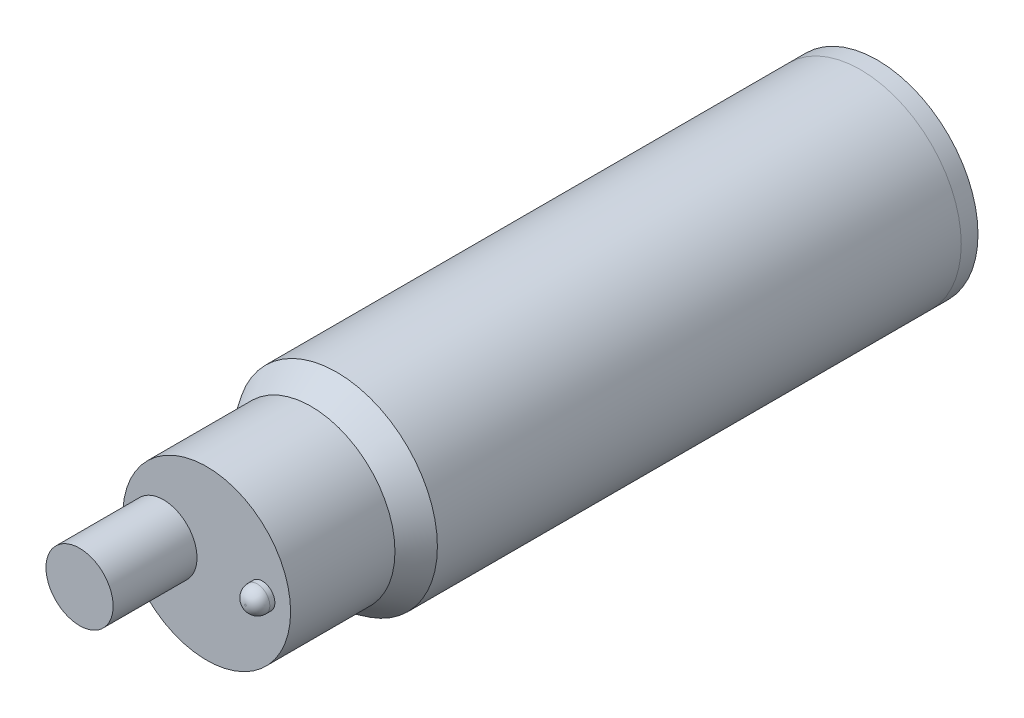
from build123d import *

# Parameters (mm, degrees)
SKETCH2_R           = 0.75
BOSS_EXTRUDE1_DEPTH = 1
FILLET1_R           = 0.7
SKETCH3_R           = 2
BOSS_EXTRUDE2_DEPTH = 5
SKETCH4_R           = 6
BOSS_EXTRUDE3_DEPTH = 1


with BuildPart() as part:
    # Sketch1 → Revolve1 (revolve)
    with BuildSketch(Plane(origin=(0, 0, 0), x_dir=(1, 0, 0), z_dir=(0, 1, 0)), mode=Mode.PRIVATE) as revolve1_sk:
        Polygon((0, 31.22), (0, 0), (1, -1.528489116), (1, -7.748489116), (6, -7.748489116), (6, 31.22), align=None)
    revolve(revolve1_sk.sketch.rotate(Axis((6, 0, 7.748489116), (0, 0, -1)), 180), axis=Axis((6, 0, 7.748489116), (0, 0, -1)))

    # Sketch2 → Boss-Extrude1 (add)
    with BuildSketch(Plane.XY.offset(7.748489116)):
        with Locations(Location((9.311049148, 0, 0), (0, 0, 180))):
            Circle(SKETCH2_R)
    extrude(amount=BOSS_EXTRUDE1_DEPTH)

    # Fillet1
    fillet1_edges = [part.edges().sort_by_distance(p)[0] for p in [
        (10.061049148, 0, 8.748489116),
    ]]
    fillet(fillet1_edges, radius=FILLET1_R)

    # Sketch3 → Boss-Extrude2 (add)
    with BuildSketch(Plane.XY.offset(7.748489116)):
        with Locations(Location((3.423004201, 0, 0), (0, 0, 180))):
            Circle(SKETCH3_R)
    extrude(amount=BOSS_EXTRUDE2_DEPTH)

    # Sketch4 → Boss-Extrude3 (add)
    with BuildSketch(Plane(origin=(0, 0, -31.22), x_dir=(-1, 0, 0), z_dir=(0, 0, -1))):
        with Locations((-5.996963967, 0)):
            Circle(SKETCH4_R)
    extrude(amount=BOSS_EXTRUDE3_DEPTH)


solid = part.part
